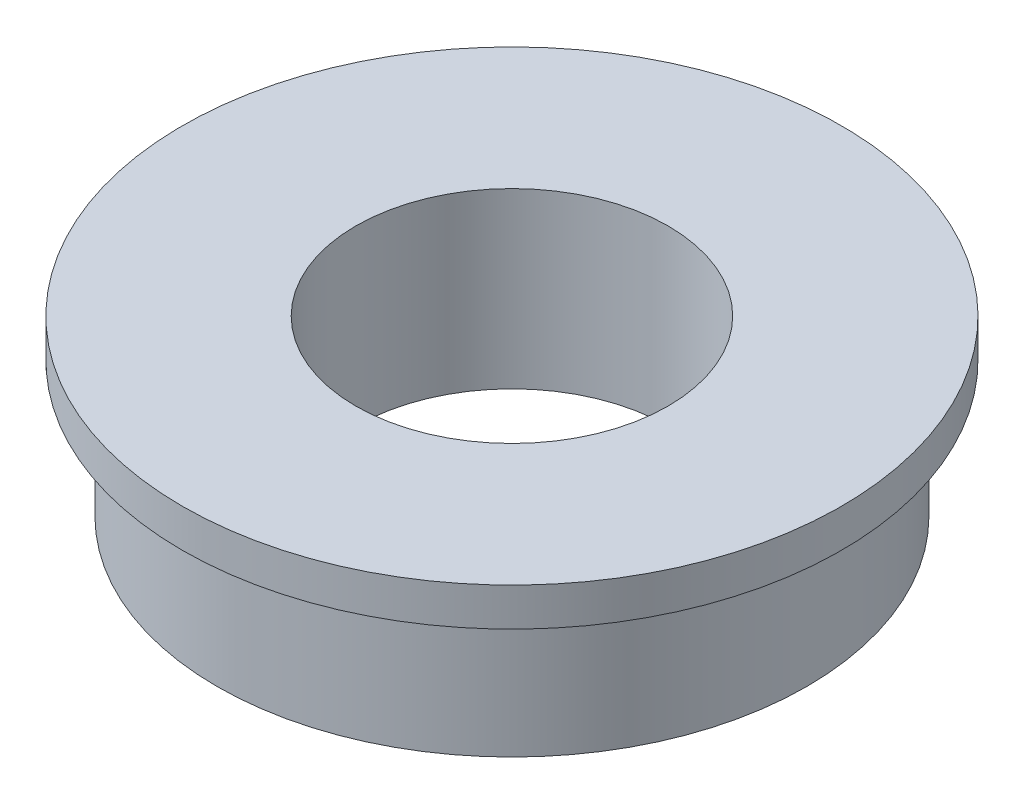
from build123d import *

# Parameters (mm, degrees)
SKETCH2_R           = 8.5
SKETCH2_R_2         = 4.5
BOSS_EXTRUDE1_DEPTH = 5
SKETCH3_R           = 9.5
SKETCH3_R_2         = 8.5
BOSS_EXTRUDE2_DEPTH = 1.1


with BuildPart() as part:
    # Sketch2 → Boss-Extrude1 (new body)
    with BuildSketch(Plane(origin=(0, 0, 0), x_dir=(1, 0, 0), z_dir=(0, 1, 0))):
        Circle(SKETCH2_R)
        Circle(SKETCH2_R_2, mode=Mode.SUBTRACT)
    extrude(amount=BOSS_EXTRUDE1_DEPTH)

    # Sketch3 → Boss-Extrude2 (add)
    with BuildSketch(Plane(origin=(0, 5, 0), x_dir=(1, 0, 0), z_dir=(0, 1, 0))):
        Circle(SKETCH3_R)
        Circle(SKETCH3_R_2, mode=Mode.SUBTRACT)
    extrude(amount=-BOSS_EXTRUDE2_DEPTH)


solid = part.part
